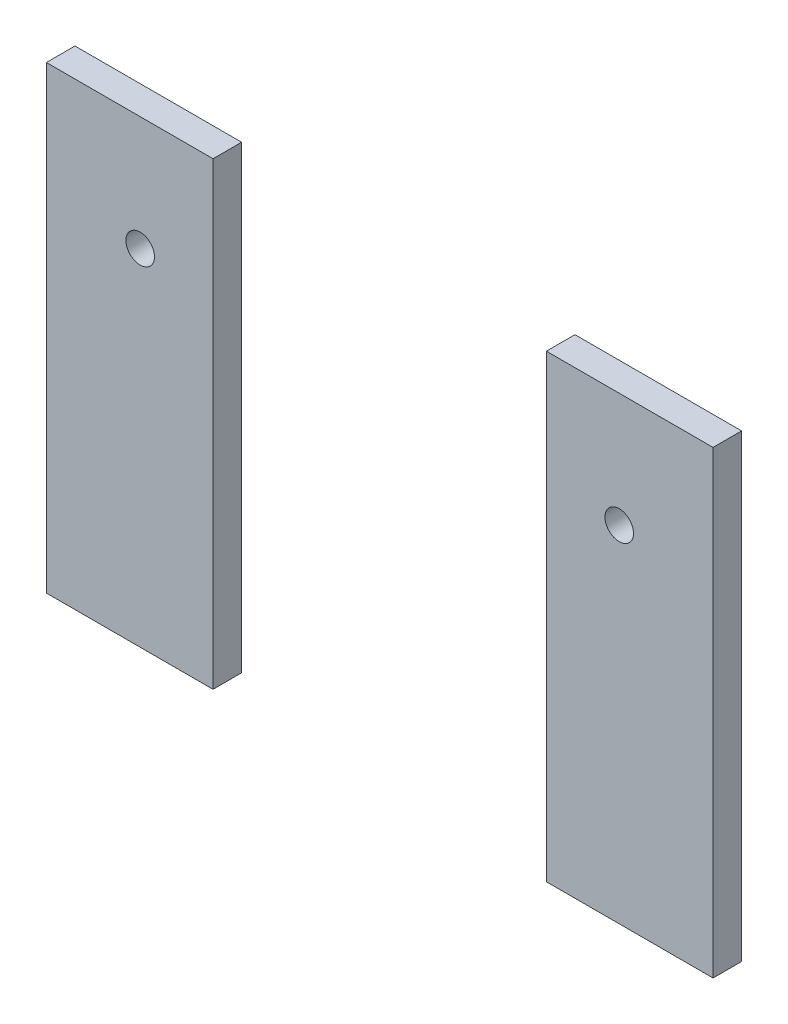
from build123d import *

# Parameters (mm, degrees)
SKETCH1_W           = 140
SKETCH1_H           = 165
BOSS_EXTRUDE1_DEPTH = 6
FILLET1_R           = 10
SKETCH9_R           = 3
CUT_EXTRUDE1_DEPTH  = 10
SKETCH10_W          = 70
SKETCH10_H          = 195.841362381
CUT_EXTRUDE2_DEPTH  = 10
SKETCH11_W          = 172.77482736
SKETCH11_H          = 74.169235041
CUT_EXTRUDE4_DEPTH  = 10


with BuildPart() as part:
    # Sketch1 → Boss-Extrude1 (new body)
    with BuildSketch(Plane.XY):
        with Locations((0, -20)):
            Rectangle(SKETCH1_W, SKETCH1_H)
    extrude(amount=BOSS_EXTRUDE1_DEPTH)

    # Fillet1
    fillet1_edges = [part.edges().sort_by_distance(p)[0] for p in [
        (-70, 62.5, 3),
        (70, 62.5, 3),
    ]]
    fillet(fillet1_edges, radius=FILLET1_R)

    # Sketch9 → Cut-Extrude1 (cut)
    with BuildSketch(Plane.XY.offset(6)):
        with Locations((50.3, 30)):
            Circle(SKETCH9_R)
        with Locations((50.3, -30)):
            Circle(SKETCH9_R)
        with Locations((-50.3, 30)):
            Circle(SKETCH9_R)
        with Locations((-50.3, -30)):
            Circle(SKETCH9_R)
    extrude(amount=-CUT_EXTRUDE1_DEPTH, mode=Mode.SUBTRACT)

    # Sketch10 → Cut-Extrude2 (cut)
    with BuildSketch(Plane.XY.offset(6)):
        with Locations((0, -19.291507384)):
            Rectangle(SKETCH10_W, SKETCH10_H)
    extrude(amount=-CUT_EXTRUDE2_DEPTH, mode=Mode.SUBTRACT)

    # Sketch11 → Cut-Extrude4 (cut)
    with BuildSketch(Plane.XY.offset(6)):
        with Locations((1.670358486, 31.084617521)):
            Rectangle(SKETCH11_W, SKETCH11_H)
    extrude(amount=-CUT_EXTRUDE4_DEPTH, mode=Mode.SUBTRACT)


solid = part.part
